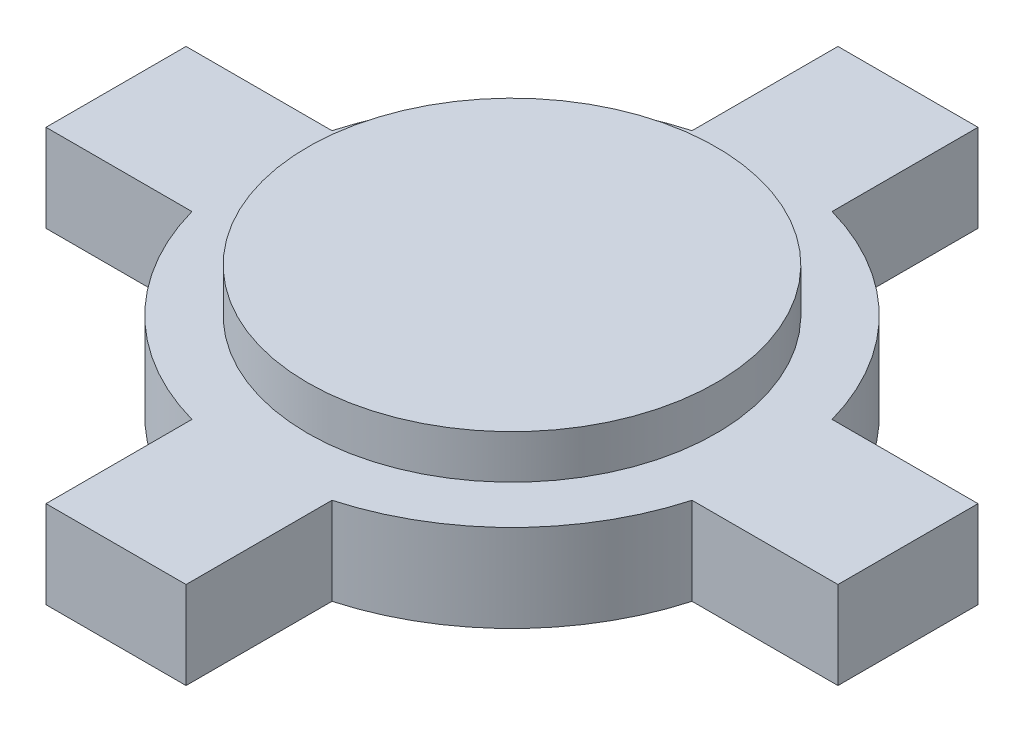
from build123d import *

# Parameters (mm, degrees)
EXTRUDE_1_DEPTH = 3
SKETCH_2_R      = 7
EXTRUDE_2_DEPTH = 1.5


with BuildPart() as part:
    # 草图1 → 凸台-拉伸1 (new body)
    with BuildSketch(Plane(origin=(0, 0, 0), x_dir=(1, 0, 0), z_dir=(0, 1, 0))):
        with BuildLine():
            Line((-13.570297544, 2.4), (-8.570297544, 2.4))
            ThreePointArc((-8.570297544, 2.4), (-6.293250353, 6.293250353), (-2.4, 8.570297544))
            Line((-2.4, 8.570297544), (-2.4, 13.570297544))
            Line((-2.4, 13.570297544), (2.4, 13.570297544))
            Line((2.4, 13.570297544), (2.4, 8.570297544))
            ThreePointArc((2.4, 8.570297544), (6.293250353, 6.293250353), (8.570297544, 2.4))
            Line((8.570297544, 2.4), (13.570297544, 2.4))
            Line((13.570297544, 2.4), (13.570297544, -2.4))
            Line((13.570297544, -2.4), (8.570297544, -2.4))
            ThreePointArc((8.570297544, -2.4), (6.293250353, -6.293250353), (2.4, -8.570297544))
            Line((2.4, -8.570297544), (2.4, -13.570297544))
            Line((2.4, -13.570297544), (-2.4, -13.570297544))
            Line((-2.4, -13.570297544), (-2.4, -8.570297544))
            ThreePointArc((-2.4, -8.570297544), (-6.293250353, -6.293250353), (-8.570297544, -2.4))
            Line((-8.570297544, -2.4), (-13.570297544, -2.4))
            Line((-13.570297544, -2.4), (-13.570297544, 2.4))
        make_face()
    extrude(amount=EXTRUDE_1_DEPTH)

    # 草图2 → 凸台-拉伸2 (add)
    with BuildSketch(Plane(origin=(0, 3, 0), x_dir=(1, 0, 0), z_dir=(0, 1, 0))):
        Circle(SKETCH_2_R)
    extrude(amount=EXTRUDE_2_DEPTH)


solid = part.part
